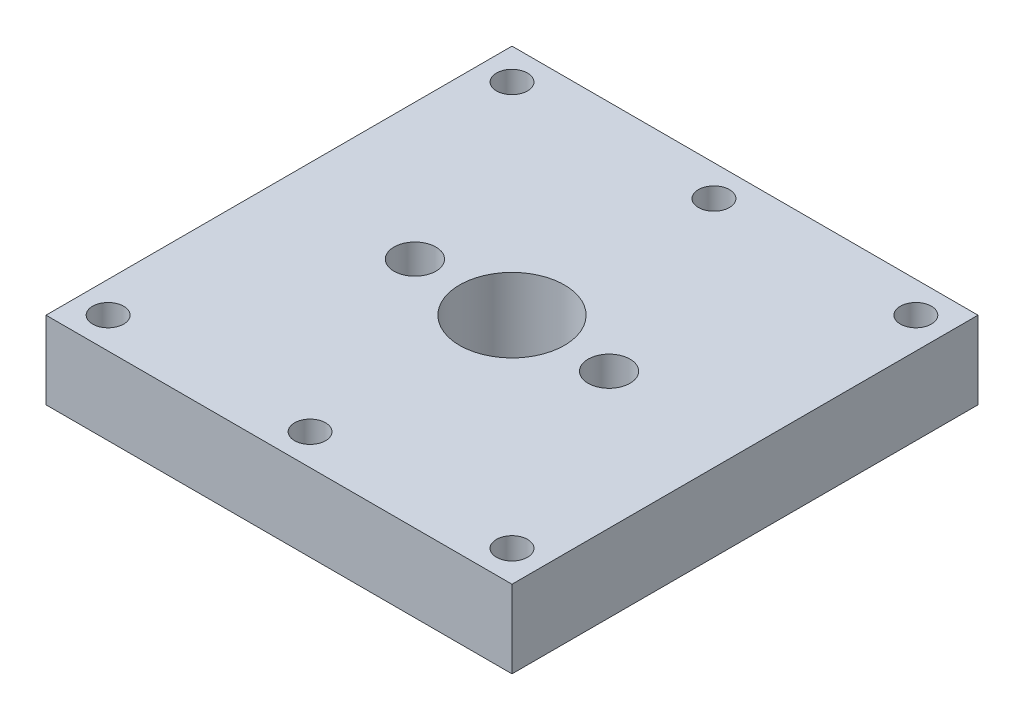
from build123d import *

# Parameters (mm, degrees)
SKETCH2_W           = 60
SKETCH2_H           = 60
BOSS_EXTRUDE1_DEPTH = 10
SKETCH3_R           = 2
CUT_EXTRUDE1_DEPTH  = 10
SKETCH5_R           = 2.7
CUT_EXTRUDE3_DEPTH  = 7
SKETCH6_R           = 0.5
CUT_EXTRUDE4_DEPTH  = 3
SKETCH7_R           = 6.75
CUT_EXTRUDE5_DEPTH  = 10


with BuildPart() as part:
    # Sketch2 → Boss-Extrude1 (new body)
    with BuildSketch(Plane(origin=(0, 0, 0), x_dir=(1, 0, 0), z_dir=(0, 1, 0))):
        Rectangle(SKETCH2_W, SKETCH2_H)
    extrude(amount=BOSS_EXTRUDE1_DEPTH)

    # Sketch3 → Cut-Extrude1 (cut)
    with BuildSketch(Plane(origin=(0, 10, 0), x_dir=(1, 0, 0), z_dir=(0, 1, 0))):
        with Locations((-26, 26)):
            Circle(SKETCH3_R)
        with Locations((-26, -26)):
            Circle(SKETCH3_R)
        with Locations((0, -26)):
            Circle(SKETCH3_R)
        with Locations((26, -26)):
            Circle(SKETCH3_R)
        with Locations((26, 26)):
            Circle(SKETCH3_R)
        with Locations((0, 26)):
            Circle(SKETCH3_R)
    extrude(amount=-CUT_EXTRUDE1_DEPTH, mode=Mode.SUBTRACT)

    # Sketch5 → Cut-Extrude3 (cut)
    with BuildSketch(Plane(origin=(0, 10, 0), x_dir=(1, 0, 0), z_dir=(0, 1, 0))):
        with Locations((12.5, 0)):
            Circle(SKETCH5_R)
        with Locations((-12.5, 0)):
            Circle(SKETCH5_R)
    extrude(amount=-CUT_EXTRUDE3_DEPTH, mode=Mode.SUBTRACT)

    # Sketch6 → Cut-Extrude4 (cut)
    with BuildSketch(Plane.XZ):
        with Locations((12.5, 0)):
            Circle(SKETCH6_R)
        with Locations((-12.5, 0)):
            Circle(SKETCH6_R)
    extrude(amount=-CUT_EXTRUDE4_DEPTH, mode=Mode.SUBTRACT)

    # Sketch7 → Cut-Extrude5 (cut)
    with BuildSketch(Plane(origin=(0, 10, 0), x_dir=(1, 0, 0), z_dir=(0, 1, 0))):
        Circle(SKETCH7_R)
    extrude(amount=-CUT_EXTRUDE5_DEPTH, mode=Mode.SUBTRACT)


solid = part.part
